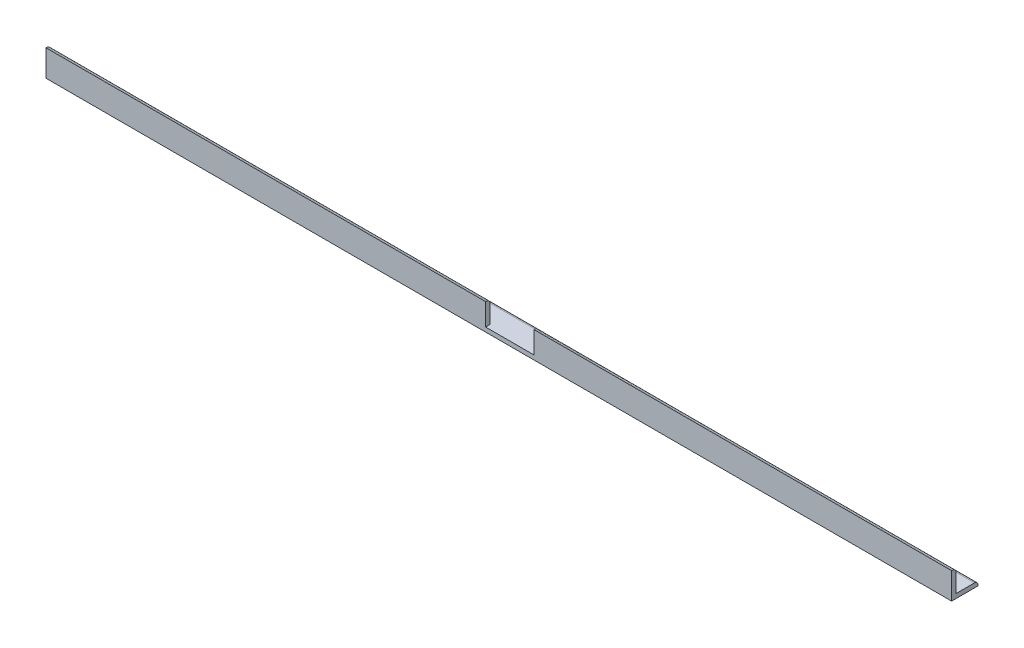
from build123d import *

# Parameters (mm, degrees)
BOSS_EXTRUDE1_DEPTH = 654.07286
CUT_EXTRUDE1_REACH  = 5.175
SKETCH2_R           = 2.54
SKETCH3_W           = 34.925
SKETCH3_H           = 49.342597017
CUT_EXTRUDE2_DEPTH  = 4.175


with BuildPart() as part:
    # Sketch1 → Boss-Extrude1 (new body)
    with BuildSketch(Plane(origin=(0, 0, 0), x_dir=(0, 0, -1), z_dir=(1, 0, 0))):
        with BuildLine():
            Line((3.175, 3.175), (16.51, 3.175))
            ThreePointArc((16.51, 3.175), (18.306051224, 2.431051224), (19.05, 0.635))
            Line((19.05, 0.635), (19.05, 0))
            Line((19.05, 0), (0, 0))
            Line((0, 0), (0, 19.05))
            Line((0, 19.05), (0.635, 19.05))
            ThreePointArc((0.635, 19.05), (2.431051224, 18.306051224), (3.175, 16.51))
            Line((3.175, 16.51), (3.175, 3.175))
        make_face()
    extrude(amount=BOSS_EXTRUDE1_DEPTH)

    # Sketch2 → Cut-Extrude1 (cut, up to next)
    with BuildSketch(Plane(origin=(0, 3.175, 0), x_dir=(1, 0, 0), z_dir=(0, 1, 0)), mode=Mode.PRIVATE) as cut_extrude1_sk1:
        with Locations((641.37286, 9.8425)):
            Circle(SKETCH2_R)
    cut_extrude1_tool1 = extrude(cut_extrude1_sk1.sketch, amount=-CUT_EXTRUDE1_REACH, mode=Mode.PRIVATE) & part.part
    add(cut_extrude1_tool1.solids().sort_by_distance((641.37286, 3.175, -9.8425))[0], mode=Mode.SUBTRACT)
    # Sketch2 → Cut-Extrude1 (cut, up to next)
    with BuildSketch(Plane(origin=(0, 3.175, 0), x_dir=(1, 0, 0), z_dir=(0, 1, 0)), mode=Mode.PRIVATE) as cut_extrude1_sk2:
        with Locations((12.7, 9.8425)):
            Circle(SKETCH2_R)
    cut_extrude1_tool2 = extrude(cut_extrude1_sk2.sketch, amount=-CUT_EXTRUDE1_REACH, mode=Mode.PRIVATE) & part.part
    add(cut_extrude1_tool2.solids().sort_by_distance((12.7, 3.175, -9.8425))[0], mode=Mode.SUBTRACT)

    # Sketch3 → Cut-Extrude2 (cut, through all)
    with BuildSketch(Plane(origin=(0, 0, -3.175), x_dir=(-1, 0, 0), z_dir=(0, 0, -1))):
        with Locations((-334.98536, 27.846298508)):
            Rectangle(SKETCH3_W, SKETCH3_H)
    extrude(amount=-CUT_EXTRUDE2_DEPTH, mode=Mode.SUBTRACT)


solid = part.part
